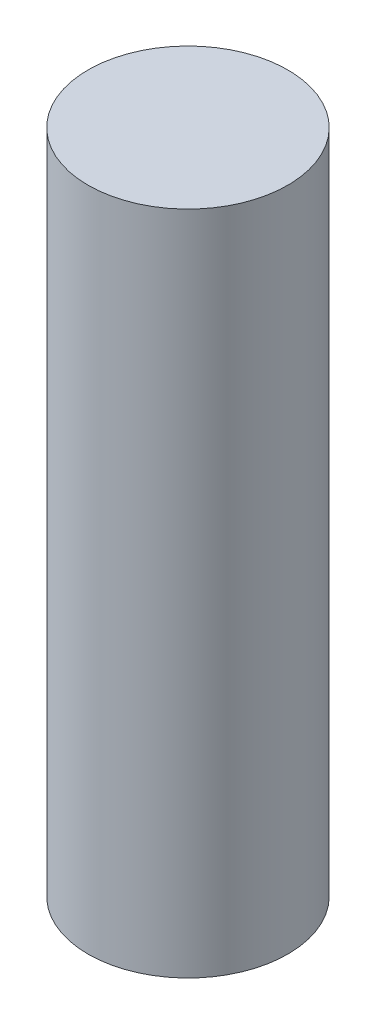
from build123d import *

# Parameters (mm, degrees)
SKETCH1_R           = 45
BOSS_EXTRUDE1_DEPTH = 300


with BuildPart() as part:
    # Sketch1 → Boss-Extrude1 (new body)
    with BuildSketch(Plane(origin=(0, 0, 0), x_dir=(1, 0, 0), z_dir=(0, 1, 0))):
        Circle(SKETCH1_R)
    extrude(amount=BOSS_EXTRUDE1_DEPTH)


solid = part.part
